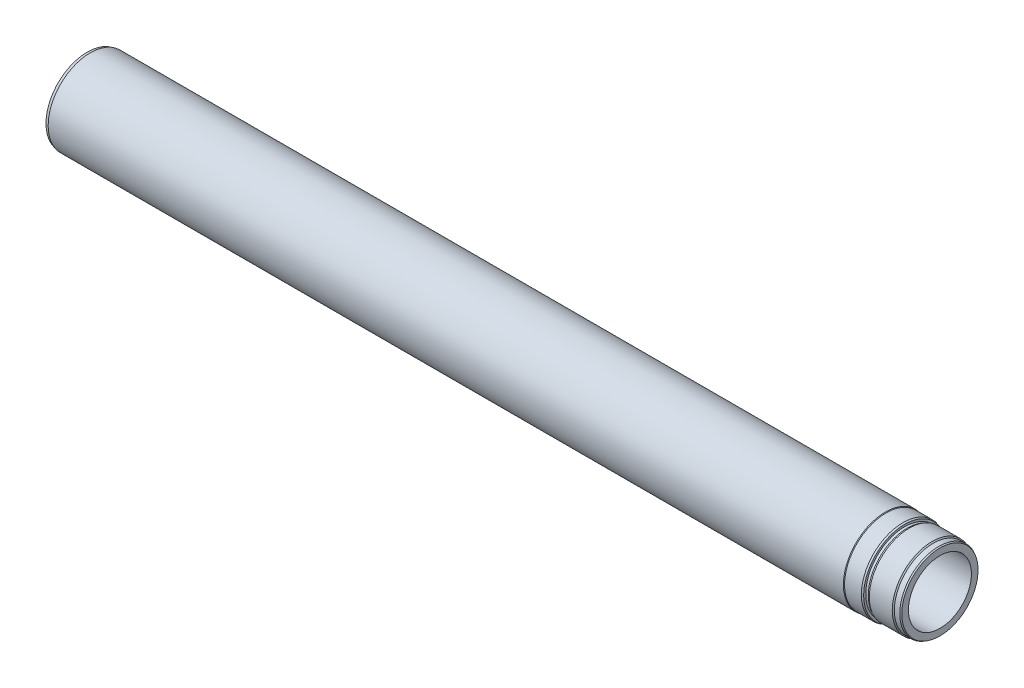
from build123d import *


with BuildPart() as part:
    # Sketch1 → Base-Revolve (revolve)
    with BuildSketch(Plane.XY):
        Polygon((0, 37.5), (0, 45.383974596), (-1.5, 46.25), (-8, 46.25), (-9.25, 47.5), (-36.546736868, 47.5), (-39, 46.25), (-42, 46.25), (-42, 48.772059531), (-44, 49.5), (-64, 49.5), (-64.866025404, 50), (-1011, 50), (-1014.5, 49.062177826), (-1014.5, 41.75), (-1013, 40.25), (-992.5, 40.25), (-990.192042299, 38.9175), (-939.5, 38.9175), (-931.460958021, 37.5), align=None)
    revolve(axis=Axis((-1014.5, 0, 0), (1, 0, 0)))


solid = part.part
